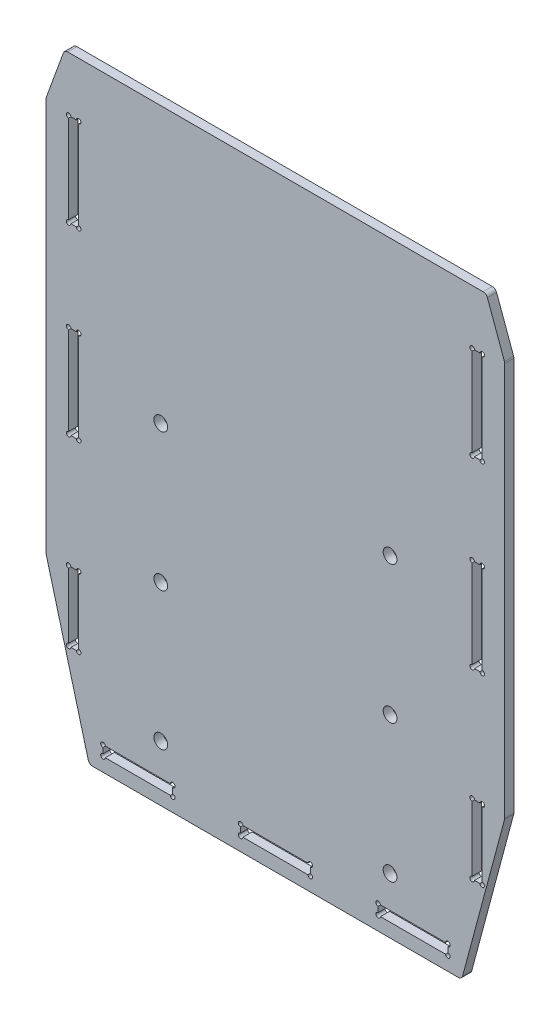
from build123d import *

# Parameters (mm, degrees)
SKETCH_1_W          = 100
SKETCH_1_H          = 132.2
SKETCH_1_W_2        = 15.2
SKETCH_1_H_2        = 2.2
SKETCH_1_W_3        = 2.2
SKETCH_1_H_3        = 15.2
SKETCH_1_H_4        = 20.2
EXTRUDE_1_DEPTH     = 2
CUT_EXTRUDE_1_DEPTH = 3
SKETCH_4_R          = 1.5
CUT_EXTRUDE_2_DEPTH = 10
SKETCH_2_R          = 0.5
CUT_EXTRUDE_3_DEPTH = 3
FILLET_1_R          = 1


with BuildPart() as part:
    # 草图1 → 凸台-拉伸1 (new body)
    with BuildSketch(Plane.XY):
        with Locations((0, -10)):
            Rectangle(SKETCH_1_W, SKETCH_1_H)
        with Locations((-30, -72)):
            Rectangle(SKETCH_1_W_2, SKETCH_1_H_2, mode=Mode.SUBTRACT)
        with Locations((-44, -48.4)):
            Rectangle(SKETCH_1_W_3, SKETCH_1_H_3, mode=Mode.SUBTRACT)
        with Locations((-44, -5.9)):
            Rectangle(SKETCH_1_W_3, SKETCH_1_H_4, mode=Mode.SUBTRACT)
        with Locations((0, -72)):
            Rectangle(SKETCH_1_W_2, SKETCH_1_H_2, mode=Mode.SUBTRACT)
        with Locations((30, -72)):
            Rectangle(SKETCH_1_W_2, SKETCH_1_H_2, mode=Mode.SUBTRACT)
        with Locations((44, -48.4)):
            Rectangle(SKETCH_1_W_3, SKETCH_1_H_3, mode=Mode.SUBTRACT)
        with Locations((44, -5.9)):
            Rectangle(SKETCH_1_W_3, SKETCH_1_H_4, mode=Mode.SUBTRACT)
        with Locations((-44, 34.1)):
            Rectangle(SKETCH_1_W_3, SKETCH_1_H_4, mode=Mode.SUBTRACT)
        with Locations((44, 34.1)):
            Rectangle(SKETCH_1_W_3, SKETCH_1_H_4, mode=Mode.SUBTRACT)
    extrude(amount=EXTRUDE_1_DEPTH)

    # 草图3 → 切除-拉伸1 (cut, through all)
    with BuildSketch(Plane(origin=(0, 0, 0), x_dir=(-1, 0, 0), z_dir=(0, 0, -1))):
        Polygon((50, 45.1), (50, 56.1), (45.996327423, 56.1), align=None)
        Polygon((-50, 45.1), (-50, 56.1), (-45.996327423, 56.1), align=None)
        Polygon((-50, -41.1), (-40.621778265, -76.1), (-50, -76.1), align=None)
        Polygon((40.621778265, -76.1), (50, -76.1), (50, -41.1), align=None)
    extrude(amount=-CUT_EXTRUDE_1_DEPTH, mode=Mode.SUBTRACT)

    # 草图4 → 切除-拉伸2 (cut)
    with BuildSketch(Plane.XY.offset(2)):
        with Locations((-25, -3.9)):
            Circle(SKETCH_4_R)
        with Locations((25, -3.9)):
            Circle(SKETCH_4_R)
        with Locations((-25, -33.9)):
            Circle(SKETCH_4_R)
        with Locations((25, -33.9)):
            Circle(SKETCH_4_R)
        with Locations((25, -63.9)):
            Circle(SKETCH_4_R)
        with Locations((-25, -63.9)):
            Circle(SKETCH_4_R)
    extrude(amount=-CUT_EXTRUDE_2_DEPTH, mode=Mode.SUBTRACT)

    # 草图2 → 切除-拉伸3 (cut, through all)
    with BuildSketch(Plane.XY.offset(2)):
        with Locations((-45.1, 44.2)):
            Circle(SKETCH_2_R)
        with Locations((-42.9, 44.2)):
            Circle(SKETCH_2_R)
        with Locations((-45.1, 24)):
            Circle(SKETCH_2_R)
        with Locations((-42.9, 24)):
            Circle(SKETCH_2_R)
        with Locations((-45.1, 4.2)):
            Circle(SKETCH_2_R)
        with Locations((-42.9, 4.2)):
            Circle(SKETCH_2_R)
        with Locations((-45.1, -16)):
            Circle(SKETCH_2_R)
        with Locations((-42.9, -16)):
            Circle(SKETCH_2_R)
        with Locations((-45.1, -40.8)):
            Circle(SKETCH_2_R)
        with Locations((-42.9, -40.8)):
            Circle(SKETCH_2_R)
        with Locations((-45.1, -56)):
            Circle(SKETCH_2_R)
        with Locations((-42.9, -56)):
            Circle(SKETCH_2_R)
        with Locations((-37.6, -70.9)):
            Circle(SKETCH_2_R)
        with Locations((-37.6, -73.1)):
            Circle(SKETCH_2_R)
        with Locations((-22.4, -70.9)):
            Circle(SKETCH_2_R)
        with Locations((-22.4, -73.1)):
            Circle(SKETCH_2_R)
        with Locations((-7.6, -70.9)):
            Circle(SKETCH_2_R)
        with Locations((-7.6, -73.1)):
            Circle(SKETCH_2_R)
        with Locations((7.6, -73.1)):
            Circle(SKETCH_2_R)
        with Locations((7.6, -70.9)):
            Circle(SKETCH_2_R)
        with Locations((22.4, -73.1)):
            Circle(SKETCH_2_R)
        with Locations((22.4, -70.9)):
            Circle(SKETCH_2_R)
        with Locations((37.6, -73.1)):
            Circle(SKETCH_2_R)
        with Locations((37.6, -70.9)):
            Circle(SKETCH_2_R)
        with Locations((42.9, -56)):
            Circle(SKETCH_2_R)
        with Locations((45.1, -56)):
            Circle(SKETCH_2_R)
        with Locations((42.9, -40.8)):
            Circle(SKETCH_2_R)
        with Locations((45.1, -40.8)):
            Circle(SKETCH_2_R)
        with Locations((42.9, -16)):
            Circle(SKETCH_2_R)
        with Locations((45.1, -16)):
            Circle(SKETCH_2_R)
        with Locations((42.9, 4.2)):
            Circle(SKETCH_2_R)
        with Locations((45.1, 4.2)):
            Circle(SKETCH_2_R)
        with Locations((42.9, 24)):
            Circle(SKETCH_2_R)
        with Locations((45.1, 24)):
            Circle(SKETCH_2_R)
        with Locations((42.9, 44.2)):
            Circle(SKETCH_2_R)
        with Locations((45.1, 44.2)):
            Circle(SKETCH_2_R)
    extrude(amount=-CUT_EXTRUDE_3_DEPTH, mode=Mode.SUBTRACT)

    # 圆角1
    fillet_1_edges = [part.edges().sort_by_distance(p)[0] for p in [
        (-50, 45.1, 1),
        (-45.996327423, 56.1, 1),
        (50, -41.1, 1),
        (40.621778265, -76.1, 1),
        (-40.621778265, -76.1, 1),
        (-50, -41.1, 1),
        (45.996327423, 56.1, 1),
        (50, 45.1, 1),
    ]]
    fillet(fillet_1_edges, radius=FILLET_1_R)


solid = part.part
